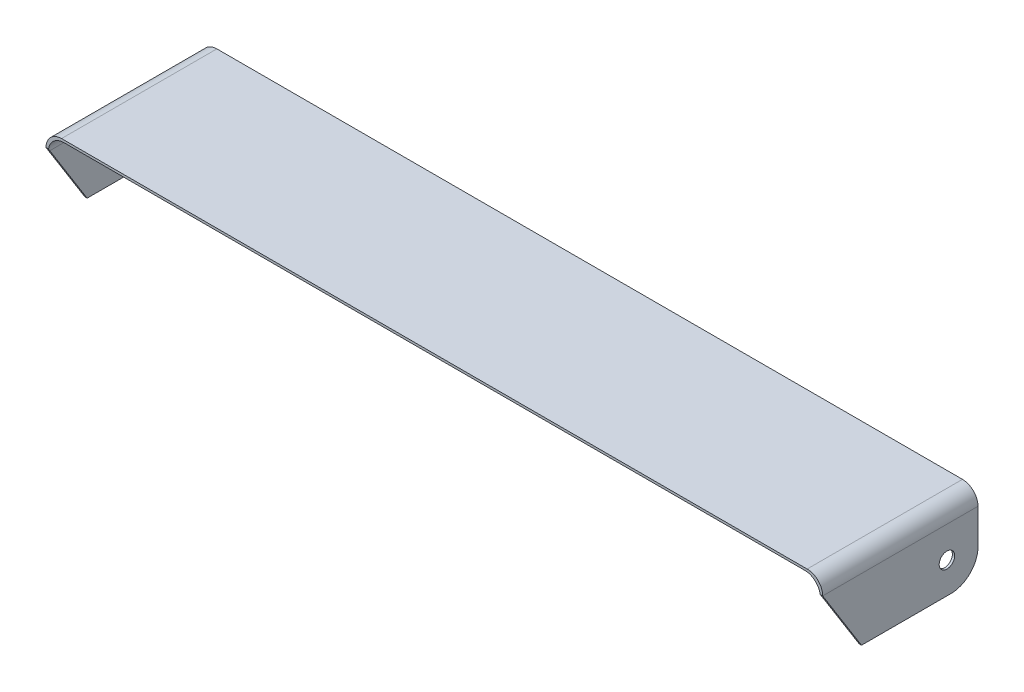
from build123d import *

# Parameters (mm, degrees)
BOSS_EXTRUDE1_DEPTH = 100
CUT_EXTRUDE1_DEPTH  = 1001
SKETCH4_R           = 10
CUT_EXTRUDE2_DEPTH  = 1001
FILLET3_R           = 35


with BuildPart() as part:
    # Sketch2 → Boss-Extrude1 (new body, symmetric)
    with BuildSketch(Plane.XY):
        with BuildLine():
            Line((0, 0), (0, 80))
            ThreePointArc((0, 80), (5.857864376, 94.142135624), (20, 100))
            Line((20, 100), (980, 100))
            ThreePointArc((980, 100), (994.142135624, 94.142135624), (1000, 80))
            Line((1000, 80), (1000, 0))
            Line((1000, 0), (997, 0))
            Line((997, 0), (997, 77))
            ThreePointArc((997, 77), (991.142135624, 91.142135624), (977, 97))
            Line((977, 97), (23, 97))
            ThreePointArc((23, 97), (8.857864376, 91.142135624), (3, 77))
            Line((3, 77), (3, 0))
            Line((3, 0), (0, 0))
        make_face()
    extrude(amount=BOSS_EXTRUDE1_DEPTH, both=True)

    # Sketch3 → Cut-Extrude1 (cut, through all)
    with BuildSketch(Plane(origin=(1000, 0, 0), x_dir=(0, 0, -1), z_dir=(1, 0, 0))):
        Polygon((-100, 0), (-50, 0), (-100, 80), align=None)
    extrude(amount=-CUT_EXTRUDE1_DEPTH, mode=Mode.SUBTRACT)

    # Sketch4 → Cut-Extrude2 (cut, through all)
    with BuildSketch(Plane(origin=(1000, 0, 0), x_dir=(0, 0, -1), z_dir=(1, 0, 0))):
        with Locations((60, 40)):
            Circle(SKETCH4_R)
    extrude(amount=-CUT_EXTRUDE2_DEPTH, mode=Mode.SUBTRACT)

    # Fillet3
    fillet3_edges = [part.edges().sort_by_distance(p)[0] for p in [
        (998.5, 0, -100),
        (1.5, 0, -100),
    ]]
    fillet(fillet3_edges, radius=FILLET3_R)


solid = part.part
